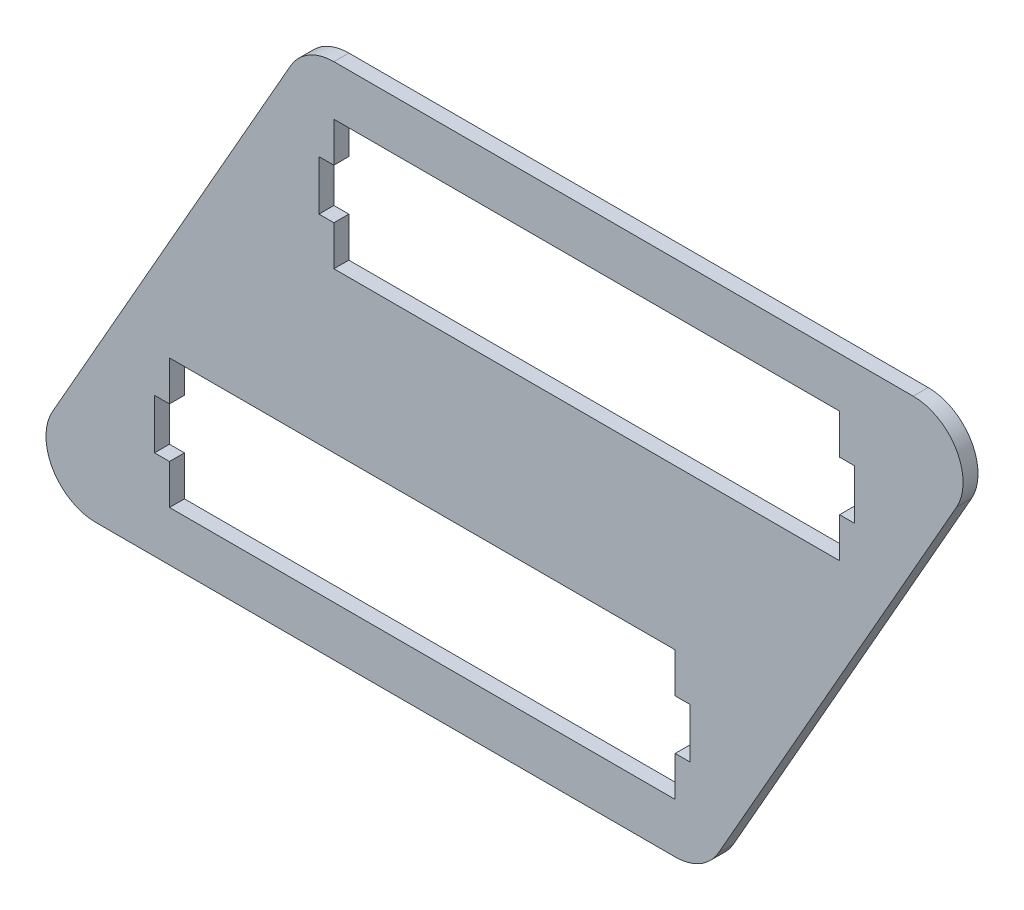
from build123d import *

# Parameters (mm, degrees)
SKIZZE1_W                       = 101.5
SKIZZE1_H                       = 26
AUFSATZ_LINEAR_AUSTRAGEN1_DEPTH = 3
VERRUNDUNG1_R                   = 10
SCHNITT_LINEAR_AUSTRAGEN2_REACH = 5
SKIZZE2_W                       = 3
SKIZZE2_H                       = 10


with BuildPart() as part:
    # Skizze1 → Aufsatz-Linear austragen1 (new body)
    with BuildSketch(Plane.XY):
        Polygon((0, 0), (59.172413793, 104), (198.476138787, 104), (139.303724994, 0), align=None)
        with Locations((82.738069394, 23)):
            Rectangle(SKIZZE1_W, SKIZZE1_H, mode=Mode.SUBTRACT)
        with Locations((115.738069394, 81)):
            Rectangle(SKIZZE1_W, SKIZZE1_H, mode=Mode.SUBTRACT)
    extrude(amount=AUFSATZ_LINEAR_AUSTRAGEN1_DEPTH)

    # Verrundung1
    verrundung1_edges = [part.edges().sort_by_distance(p)[0] for p in [
        (0, 0, 1.5),
        (59.172413793, 104, 1.5),
        (198.476138787, 104, 1.5),
        (139.303724994, 0, 1.5),
    ]]
    fillet(verrundung1_edges, radius=VERRUNDUNG1_R)

    # Skizze2 → Schnitt-Linear austragen2 (cut, up to next)
    with BuildSketch(Plane.XY.offset(3), mode=Mode.PRIVATE) as schnitt_linear_austragen2_sk1:
        with Locations((63.488069394, 81)):
            Rectangle(SKIZZE2_W, SKIZZE2_H)
    schnitt_linear_austragen2_tool1 = extrude(schnitt_linear_austragen2_sk1.sketch, amount=-SCHNITT_LINEAR_AUSTRAGEN2_REACH, mode=Mode.PRIVATE) & part.part
    add(schnitt_linear_austragen2_tool1.solids().sort_by_distance((63.488069, 81, 3))[0], mode=Mode.SUBTRACT)
    # Skizze2 → Schnitt-Linear austragen2 (cut, up to next)
    with BuildSketch(Plane.XY.offset(3), mode=Mode.PRIVATE) as schnitt_linear_austragen2_sk2:
        with Locations((167.988069394, 81)):
            Rectangle(SKIZZE2_W, SKIZZE2_H)
    schnitt_linear_austragen2_tool2 = extrude(schnitt_linear_austragen2_sk2.sketch, amount=-SCHNITT_LINEAR_AUSTRAGEN2_REACH, mode=Mode.PRIVATE) & part.part
    add(schnitt_linear_austragen2_tool2.solids().sort_by_distance((167.988069, 81, 3))[0], mode=Mode.SUBTRACT)
    # Skizze2 → Schnitt-Linear austragen2 (cut, up to next)
    with BuildSketch(Plane.XY.offset(3), mode=Mode.PRIVATE) as schnitt_linear_austragen2_sk3:
        with Locations((30.488069394, 23)):
            Rectangle(SKIZZE2_W, SKIZZE2_H)
    schnitt_linear_austragen2_tool3 = extrude(schnitt_linear_austragen2_sk3.sketch, amount=-SCHNITT_LINEAR_AUSTRAGEN2_REACH, mode=Mode.PRIVATE) & part.part
    add(schnitt_linear_austragen2_tool3.solids().sort_by_distance((30.488069, 23, 3))[0], mode=Mode.SUBTRACT)
    # Skizze2 → Schnitt-Linear austragen2 (cut, up to next)
    with BuildSketch(Plane.XY.offset(3), mode=Mode.PRIVATE) as schnitt_linear_austragen2_sk4:
        with Locations((134.988069394, 23)):
            Rectangle(SKIZZE2_W, SKIZZE2_H)
    schnitt_linear_austragen2_tool4 = extrude(schnitt_linear_austragen2_sk4.sketch, amount=-SCHNITT_LINEAR_AUSTRAGEN2_REACH, mode=Mode.PRIVATE) & part.part
    add(schnitt_linear_austragen2_tool4.solids().sort_by_distance((134.988069, 23, 3))[0], mode=Mode.SUBTRACT)


solid = part.part
